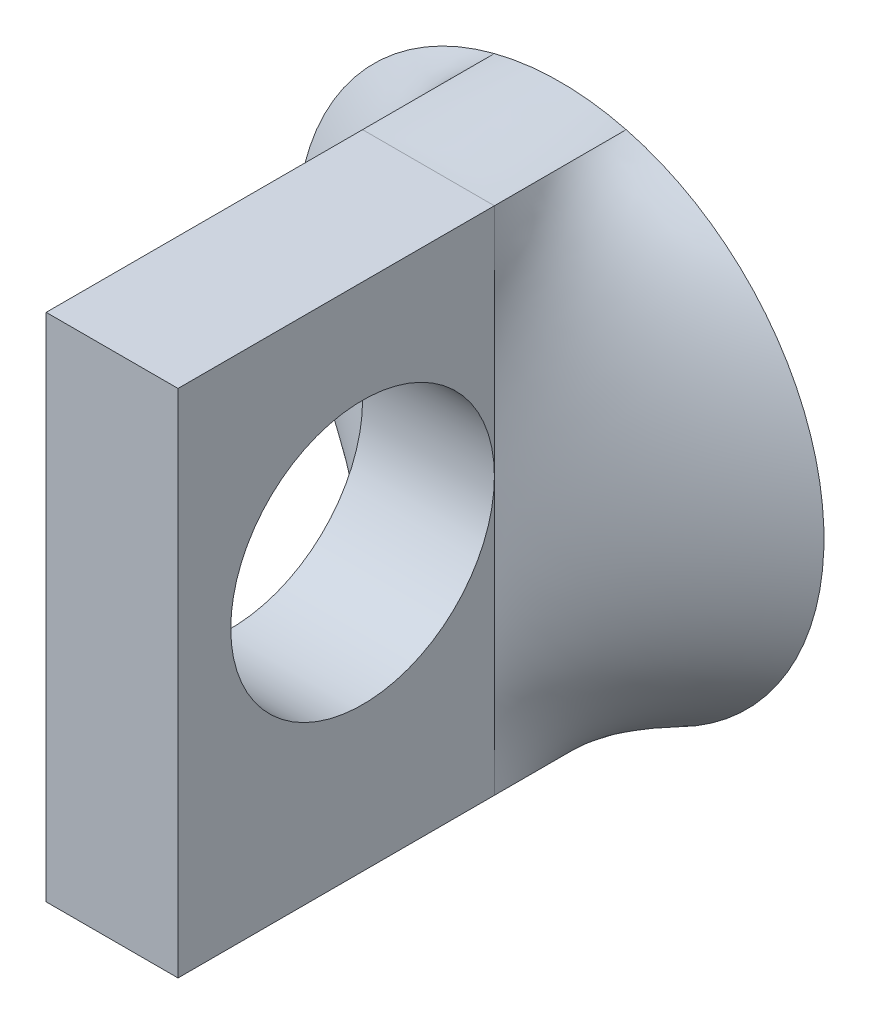
from build123d import *

# Parameters (mm, degrees)
SKETCH2_W           = 6.35
SKETCH2_H           = 24.593444248
SKETCH3_W           = 6.35
SKETCH3_H           = 24.593444248
BOSS_EXTRUDE1_DEPTH = 15.24
SKETCH4_R           = 6.35
CUT_EXTRUDE1_DEPTH  = 30.655247945


with BuildPart() as part:
    # Sketch2 → Loft1 section 0
    with BuildSketch(Plane.XY.offset(6.35)):
        Rectangle(SKETCH2_W, SKETCH2_H)
    # Sketch1 for Loft1 → Loft1 section 1
    with BuildSketch(Plane.XY):
        with BuildLine():
            # circular arc as an exact rational Bezier (weights 1, cos(half-angle), 1)
            Bezier((-3.175, 12.296722124), (0, 13.116503599), (3.175, 12.296722124), weights=[1, 0.968245837, 1])
            Bezier((3.175, 12.296722124), (50.800000002, 0), (3.175, -12.296722124), weights=[1, 0.25, 1])
            Bezier((3.175, -12.296722124), (0, -13.116503599), (-3.175, -12.296722124), weights=[1, 0.968245837, 1])
            Bezier((-3.175, -12.296722124), (-50.800000002, 0), (-3.175, 12.296722124), weights=[1, 0.25, 1])
        make_face()
    loft()

    # Sketch3 → Boss-Extrude1 (add)
    with BuildSketch(Plane.XY.offset(6.35)):
        Rectangle(SKETCH3_W, SKETCH3_H)
    extrude(amount=BOSS_EXTRUDE1_DEPTH)

    # Sketch4 → Cut-Extrude1 (cut, through all)
    with BuildSketch(Plane(origin=(3.175, 0, 0), x_dir=(0, 0, -1), z_dir=(1, 0, 0))):
        with Locations((-12.7, 1.010428855)):
            Circle(SKETCH4_R)
    extrude(amount=-CUT_EXTRUDE1_DEPTH, mode=Mode.SUBTRACT)


solid = part.part
